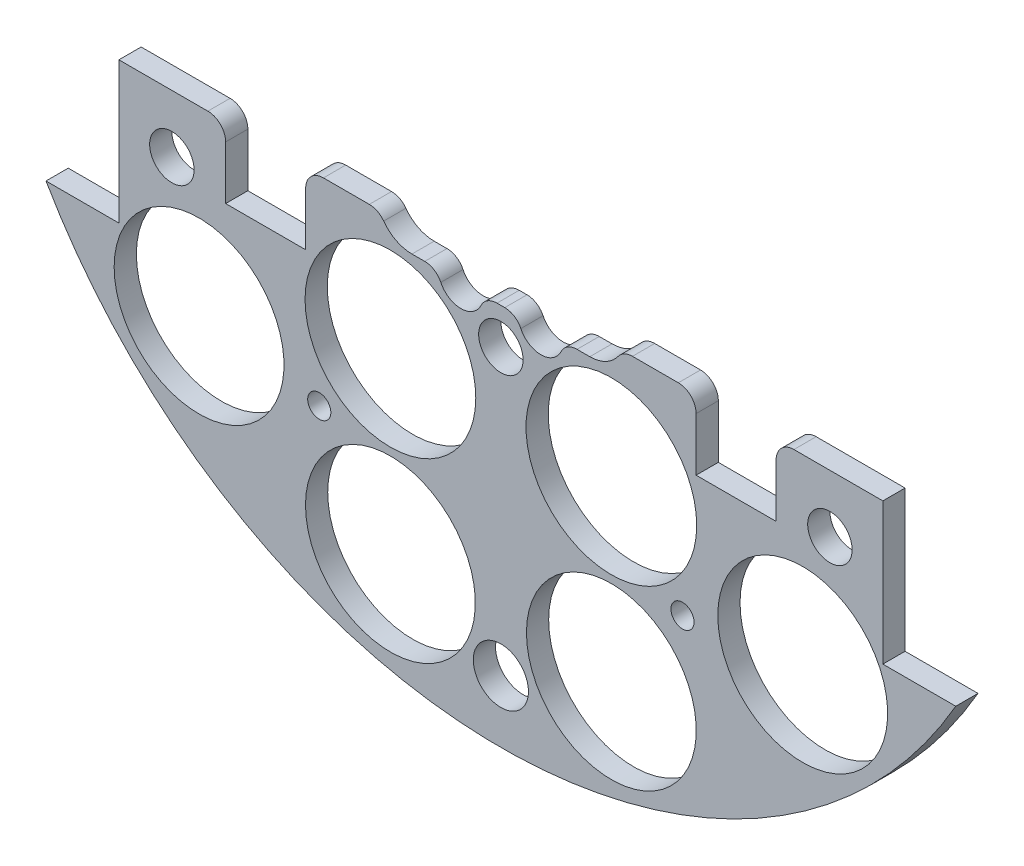
from build123d import *

# Parameters (mm, degrees)
SKETCH1_R                = 1.651
BOSS_EXTRUDE2_DEPTH      = 3.175
SKETCH2_R                = 1.143
CUT_EXTRUDE1_DEPTH       = 4.175
SKETCH3_R                = 12.1285
CUT_EXTRUDE2_DEPTH       = 4.175
SKETCH4_W                = 28.562713242
SKETCH4_H                = 11.677503754
BOSS_EXTRUDE3_DEPTH      = 3.175
SKETCH5_W                = 216.7214489
SKETCH5_H                = 130.569220634
CUT_EXTRUDE4_DEPTH       = 4.175
SKETCH11_R               = 3.937
CUT_EXTRUDE11_DEPTH      = 4.175
SKETCH12_W               = 11.43
SKETCH12_H               = 10.16
CUT_EXTRUDE12_DEPTH      = 4.175
SKETCH16_R               = 12.192
CUT_EXTRUDE16_DEPTH      = 21.59
SKETCH57_R               = 1.651
CUT_EXTRUDE57_DEPTH      = 58.674
SKETCH58_R               = 3.175
CUT_EXTRUDE58_DEPTH      = 103.378
CUT_EXTRUDE58_DEPTH_BACK = 48.768
CUT_EXTRUDE15_DEPTH      = 21.59
FILLET1_R                = 2.54


with BuildPart() as part:
    # Sketch1 → Boss-Extrude2 (new body)
    with BuildSketch(Plane.XY):
        with BuildLine():
            Line((-64.964441474, 37.338), (-54.550441474, 37.338))
            Line((-54.550441474, 37.338), (-54.550441474, -37.338))
            Line((-54.550441474, -37.338), (-64.964441474, -37.338))
            ThreePointArc((-64.964441474, -37.338), (0, -74.93), (64.964441474, -37.338))
            Line((64.964441474, -37.338), (54.550441474, -37.338))
            Line((54.550441474, -37.338), (54.550441474, 37.338))
            Line((54.550441474, 37.338), (64.964441474, 37.338))
            ThreePointArc((64.964441474, 37.338), (0, 74.93), (-64.964441474, 37.338))
        make_face()
        with Locations((-46.482, 11.049)):
            Circle(SKETCH1_R, mode=Mode.SUBTRACT)
        with Locations((-21.083270032, 10.795)):
            Circle(SKETCH1_R, mode=Mode.SUBTRACT)
        with Locations((-21.083270032, -10.795)):
            Circle(SKETCH1_R, mode=Mode.SUBTRACT)
        with Locations((-46.482, -11.049)):
            Circle(SKETCH1_R, mode=Mode.SUBTRACT)
        with Locations((46.482, -11.049)):
            Circle(SKETCH1_R, mode=Mode.SUBTRACT)
        with Locations((21.083270032, -10.795)):
            Circle(SKETCH1_R, mode=Mode.SUBTRACT)
        with Locations((21.083270032, 10.795)):
            Circle(SKETCH1_R, mode=Mode.SUBTRACT)
        with Locations((46.482, 11.049)):
            Circle(SKETCH1_R, mode=Mode.SUBTRACT)
    extrude(amount=BOSS_EXTRUDE2_DEPTH)

    # Sketch2 → Cut-Extrude1 (cut, through all)
    with BuildSketch(Plane.XY.offset(3.175)):
        with Locations((-6.731, 62.23)):
            Circle(SKETCH2_R)
        with Locations((6.731, 62.23)):
            Circle(SKETCH2_R)
    extrude(amount=-CUT_EXTRUDE1_DEPTH, mode=Mode.SUBTRACT)

    # Sketch3 → Cut-Extrude2 (cut, through all)
    with BuildSketch(Plane(origin=(0, 0, 0), x_dir=(-1, 0, 0), z_dir=(0, 0, -1))):
        with Locations((-15.777608989, -58.882838371)):
            Circle(SKETCH3_R)
        with Locations((15.777608989, -58.882838371)):
            Circle(SKETCH3_R)
        with Locations((-43.105229381, -43.105229381)):
            Circle(SKETCH3_R)
        with Locations((-43.105229381, 43.105229381)):
            Circle(SKETCH3_R)
        with Locations((43.105229381, 43.105229381)):
            Circle(SKETCH3_R)
        with Locations((43.105229381, -43.105229381)):
            Circle(SKETCH3_R)
    extrude(amount=-CUT_EXTRUDE2_DEPTH, mode=Mode.SUBTRACT)

    # Sketch4 → Boss-Extrude3 (add)
    with BuildSketch(Plane(origin=(0, 0, 0), x_dir=(-1, 0, 0), z_dir=(0, 0, -1))):
        with Locations((-1.488809975, 62.152540216)):
            Rectangle(SKETCH4_W, SKETCH4_H)
    extrude(amount=-BOSS_EXTRUDE3_DEPTH)

    # Sketch5 → Cut-Extrude4 (cut, through all)
    with BuildSketch(Plane(origin=(0, 0, 0), x_dir=(-1, 0, 0), z_dir=(0, 0, -1))):
        with Locations((23.316688373, 48.139610317)):
            Rectangle(SKETCH5_W, SKETCH5_H)
    extrude(amount=-CUT_EXTRUDE4_DEPTH, mode=Mode.SUBTRACT)

    # Sketch11 → Cut-Extrude11 (cut, through all)
    with BuildSketch(Plane(origin=(0, 0, 0), x_dir=(-1, 0, 0), z_dir=(0, 0, -1))):
        with Locations((0, -66.045)):
            Circle(SKETCH11_R)
    extrude(amount=-CUT_EXTRUDE11_DEPTH, mode=Mode.SUBTRACT)

    # Sketch12 → Cut-Extrude12 (cut, through all)
    with BuildSketch(Plane(origin=(0, 0, 0), x_dir=(-1, 0, 0), z_dir=(0, 0, -1))):
        with Locations((-33.595441474, -22.225)):
            Rectangle(SKETCH12_W, SKETCH12_H)
        with Locations((33.595441474, -22.225)):
            Rectangle(SKETCH12_W, SKETCH12_H)
    extrude(amount=-CUT_EXTRUDE12_DEPTH, mode=Mode.SUBTRACT)

    # Sketch16 → Cut-Extrude16 (cut)
    with BuildSketch(Plane(origin=(0, 0, 0), x_dir=(-1, 0, 0), z_dir=(0, 0, -1))):
        with Locations((15.777608989, -33.482838371)):
            Circle(SKETCH16_R)
        with Locations((-15.777608989, -33.482838371)):
            Circle(SKETCH16_R)
    extrude(amount=-CUT_EXTRUDE16_DEPTH, mode=Mode.SUBTRACT)

    # Sketch57 → Cut-Extrude57 (cut)
    with BuildSketch(Plane(origin=(0, 0, 0), x_dir=(-1, 0, 0), z_dir=(0, 0, -1))):
        with Locations((-25.937608989, -45.645229381)):
            Circle(SKETCH57_R)
        with Locations((25.937608989, -45.645229381)):
            Circle(SKETCH57_R)
    extrude(amount=-CUT_EXTRUDE57_DEPTH, mode=Mode.SUBTRACT)

    # Sketch58 → Cut-Extrude58 (cut, two sides)
    with BuildSketch(Plane(origin=(30.092005081, 4.08352975, 36.1315), x_dir=(-1, 0, 0), z_dir=(0, 0, -1))) as cut_extrude58_sk:
        with Locations((77.082005081, -29.48352975)):
            Circle(SKETCH58_R)
        with Locations((30.092005081, -29.48352975)):
            Circle(SKETCH58_R)
        with Locations((-16.897994919, -29.48352975)):
            Circle(SKETCH58_R)
    extrude(amount=CUT_EXTRUDE58_DEPTH, mode=Mode.SUBTRACT)
    extrude(cut_extrude58_sk.sketch, amount=-CUT_EXTRUDE58_DEPTH_BACK, mode=Mode.SUBTRACT)

    # Sketch15 → Cut-Extrude15 (cut)
    with BuildSketch(Plane(origin=(0, 0, 0), x_dir=(-1, 0, 0), z_dir=(0, 0, -1))):
        with BuildLine():
            Line((-12.7, -20.24), (-8.888991966, -20.24))
            ThreePointArc((-8.888991966, -20.24), (-5.715, -23.495), (-2.541008034, -20.24))
            Line((-2.541008034, -20.24), (2.541008034, -20.24))
            ThreePointArc((2.541008034, -20.24), (5.715, -23.495), (8.888991966, -20.24))
            Line((8.888991966, -20.24), (12.7, -20.24))
            ThreePointArc((12.7, -20.24), (16.235533906, -11.704466094), (7.7, -15.24))
            Line((7.7, -15.24), (-1.06, -15.24))
            ThreePointArc((-1.06, -15.24), (-4.010609847, -10.6792983), (-9.38, -11.501337137))
            ThreePointArc((-9.38, -11.501337137), (-17.374040774, -13.464234575), (-12.7, -20.24))
        make_face()
    extrude(amount=-CUT_EXTRUDE15_DEPTH, mode=Mode.SUBTRACT)

    # Fillet1
    fillet1_edges = [part.edges().sort_by_distance(p)[0] for p in [
        (39.310441474, -17.145, 1.5875),
        (27.880441474, -17.145, 1.5875),
        (-27.880441474, -17.145, 1.5875),
        (-39.310441474, -17.145, 1.5875),
        (-17.322875188, -17.145, 1.5875),
        (17.322875188, -17.145, 1.5875),
        (-8.888991966, -20.24, 1.5875),
        (-2.541008034, -20.24, 1.5875),
        (2.541008034, -20.24, 1.5875),
        (8.888991966, -20.24, 1.5875),
    ]]
    fillet(fillet1_edges, radius=FILLET1_R)


solid = part.part
